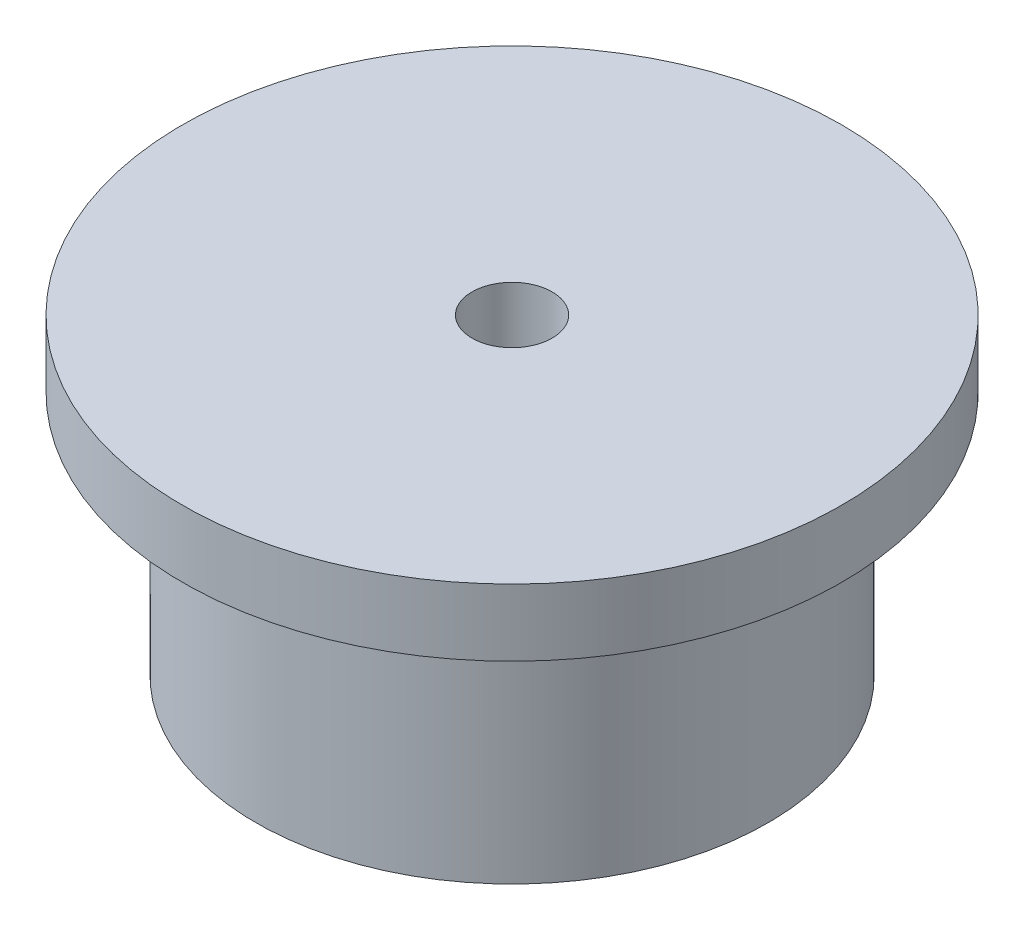
from build123d import *


with BuildPart() as part:
    # Sketch2 → Revolve1 (revolve)
    with BuildSketch(Plane(origin=(0, 0, 0), x_dir=(0, 0, -1), z_dir=(1, 0, 0))):
        Polygon((17.5, 24), (17.5, 64), (25, 64), (25, 74), (9, 74), (9, 94), (74, 94), (74, 79), (57.5, 79), (57.5, 24), align=None)
    revolve(axis=Axis((0, 0, 0), (0, 1, 0)))


solid = part.part
